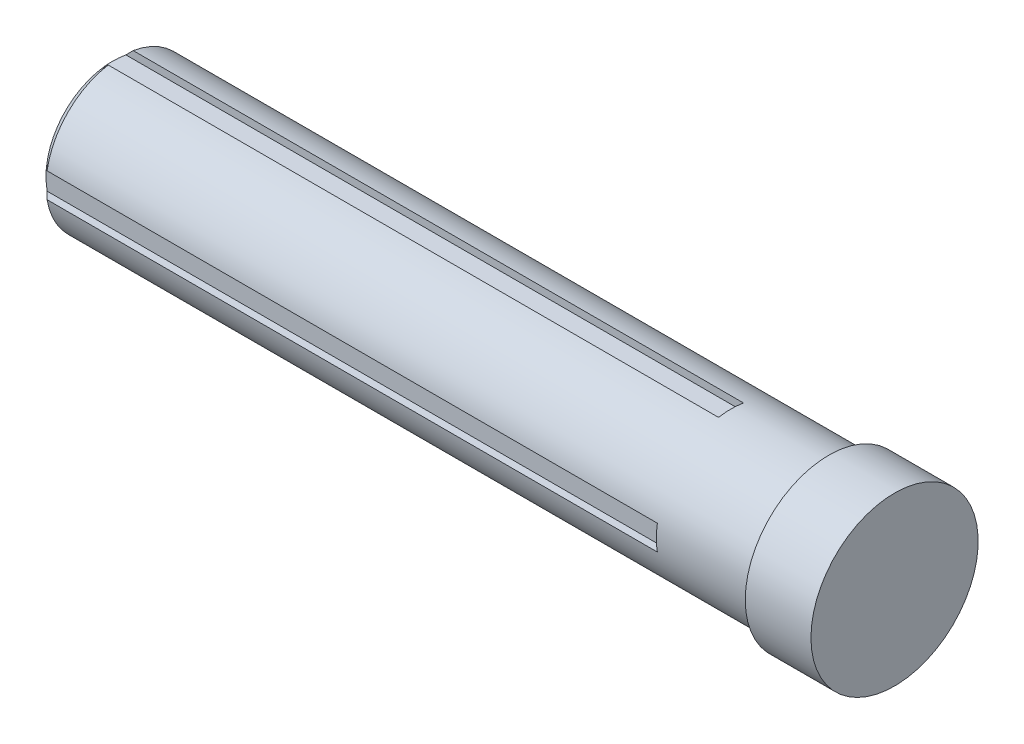
from build123d import *

# Parameters (mm, degrees)
CUT_EXTRUDE1_DEPTH = 1036.14
CIRPATTERN1_COUNT  = 4


with BuildPart() as part:
    # Sketch1 → Revolve1 (revolve)
    with BuildSketch(Plane.XY):
        Polygon((-670.560162424, 0), (-670.560162424, 110.857864376), (-656.418026801, 125), (529.439837576, 125), (529.439837576, 140), (639.439837576, 140), (639.439837576, 0), align=None)
    revolve(axis=Axis((-815.610544749, 0, 0), (1, 0, 0)))

    # Sketch2 → Cut-Extrude1 (cut)
    with BuildSketch(Plane.ZY.offset(670.560162424)):
        with BuildLine():
            Line((-20.915, 110.857864376), (20.915, 110.857864376))
            Line((20.915, 110.857864376), (20.915, 123.237830129))
            ThreePointArc((20.915, 123.237830129), (0, 125), (-20.915, 123.237830129))
            Line((-20.915, 123.237830129), (-20.915, 110.857864376))
        make_face()
    cut_extrude1 = extrude(amount=-CUT_EXTRUDE1_DEPTH, mode=Mode.SUBTRACT)

    # CirPattern1: Cut-Extrude1 ×4 about axis
    cirpattern1_axis = Axis((0, 0, 0), (1, 0, 0))
    for i in range(1, CIRPATTERN1_COUNT):
        add(cut_extrude1.rotate(cirpattern1_axis, i * 360 / CIRPATTERN1_COUNT), mode=Mode.SUBTRACT)


solid = part.part
